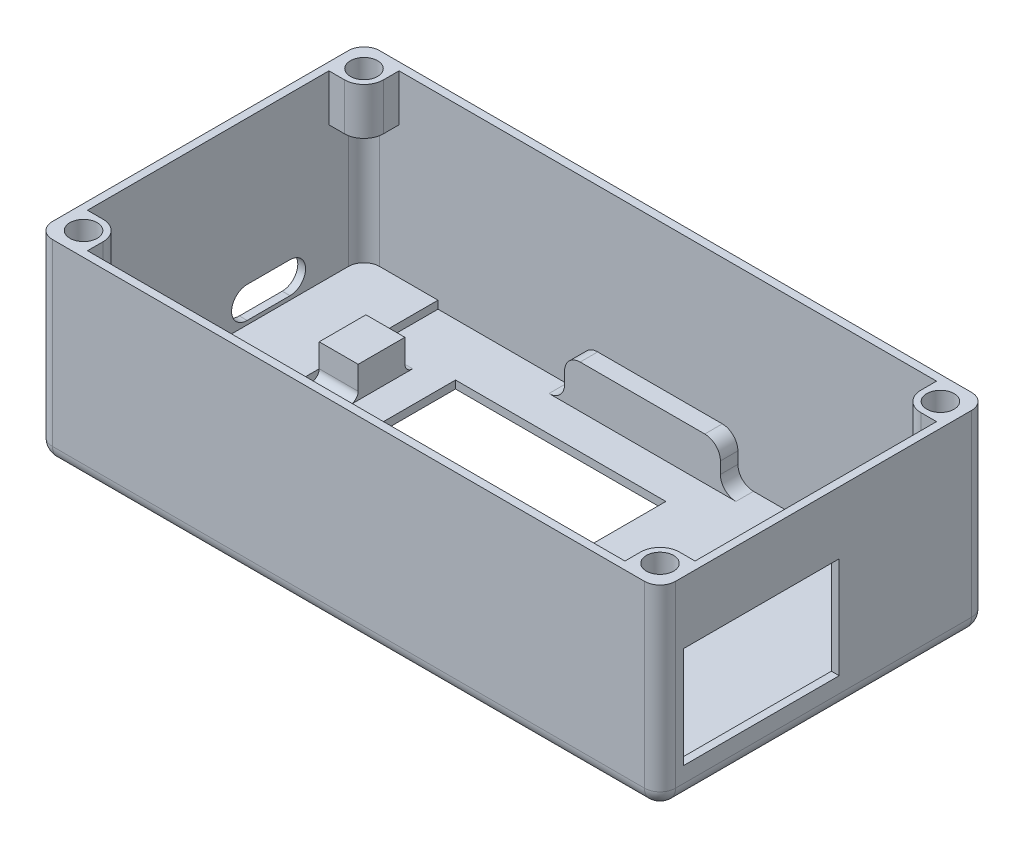
from build123d import *

# Parameters (mm, degrees)
SKETCH1_W               = 80
SKETCH1_H               = 42
BOSS_EXTRUDE1_DEPTH     = 25
SKETCH6_W               = 78
SKETCH6_H               = 40
CUT_EXTRUDE6_DEPTH      = 24
CUT_EXTRUDE7_REACH      = 53.157
SKETCH7_W               = 33.5
SKETCH7_H               = 20
SKETCH8_W               = 5
SKETCH8_H               = 6
BOSS_EXTRUDE2_DEPTH     = 4
SKETCH9_W               = 9.5
SKETCH9_H               = 25.25
BOSS_EXTRUDE3_DEPTH     = 1
FILLET1_R               = 1
FILLET3_R               = 2
CUT_EXTRUDE8_REACH      = 87.481
SKETCH18_W              = 20
SKETCH18_H              = 2.25
SKETCH18_H_2            = 3
BOSS_EXTRUDE5_DEPTH     = 5.5
FILLET5_R               = 2
CUT_EXTRUDE12_REACH     = 88.406
BOSS_EXTRUDE6_DEPTH     = 6
CUT_EXTRUDE13_REACH     = 53.633
SKETCH22_R              = 1.75
MIRROR3_COPY_1_DEPTH    = 6
MIRROR3_COPY_2_REACH    = 53.633
MIRROR3_COPY_2_SKETCH_R = 1.75
FILLET6_R               = 2
BOSS_EXTRUDE7_DEPTH     = 1
CUT_EXTRUDE14_REACH     = 88.406
SKETCH24_W              = 20
SKETCH24_H              = 13


with BuildPart() as part:
    # Sketch1 → Boss-Extrude1 (new body)
    with BuildSketch(Plane(origin=(0, 0, 0), x_dir=(1, 0, 0), z_dir=(0, 1, 0))):
        Rectangle(SKETCH1_W, SKETCH1_H)
    extrude(amount=BOSS_EXTRUDE1_DEPTH)

    # Sketch6 → Cut-Extrude6 (cut)
    with BuildSketch(Plane(origin=(0, 25, 0), x_dir=(1, 0, 0), z_dir=(0, 1, 0))):
        Rectangle(SKETCH6_W, SKETCH6_H)
    extrude(amount=-CUT_EXTRUDE6_DEPTH, mode=Mode.SUBTRACT)

    # Sketch7 → Cut-Extrude7 (cut, up to next)
    with BuildSketch(Plane(origin=(0, 1, 0), x_dir=(1, 0, 0), z_dir=(0, 1, 0)), mode=Mode.PRIVATE) as cut_extrude7_sk1:
        with Locations((-7.75, 7.75)):
            Rectangle(SKETCH7_W, SKETCH7_H)
    cut_extrude7_tool1 = extrude(cut_extrude7_sk1.sketch, amount=-CUT_EXTRUDE7_REACH, mode=Mode.PRIVATE) & part.part
    add(cut_extrude7_tool1.solids().sort_by_distance((-7.75, 1, -7.75))[0], mode=Mode.SUBTRACT)

    # Sketch8 → Boss-Extrude2 (add)
    with BuildSketch(Plane(origin=(0, 1, 0), x_dir=(1, 0, 0), z_dir=(0, 1, 0))):
        with Locations((-27, 7.75)):
            Rectangle(SKETCH8_W, SKETCH8_H)
    extrude(amount=BOSS_EXTRUDE2_DEPTH)

    # Sketch9 → Boss-Extrude3 (add)
    with BuildSketch(Plane(origin=(0, 1, 0), x_dir=(1, 0, 0), z_dir=(0, 1, 0))):
        with Locations((-34.25, 7.375)):
            Rectangle(SKETCH9_W, SKETCH9_H)
    extrude(amount=BOSS_EXTRUDE3_DEPTH)

    # Fillet1
    fillet1_edges = [part.edges().sort_by_distance(p)[0] for p in [
        (-27, 1, -10.75),
        (-27, 1, -4.75),
    ]]
    fillet(fillet1_edges, radius=FILLET1_R)

    # Fillet3
    fillet3_edges = [part.edges().sort_by_distance(p)[0] for p in [
        (-39, 13, 20),
        (39, 13, 20),
        (39, 13, -20),
        (-39, 13.5, -20),
        (40, 12.5, 21),
        (-40, 12.5, 21),
        (-40, 12.5, -21),
        (40, 12.5, -21),
    ]]
    fillet(fillet3_edges, radius=FILLET3_R)

    # Sketch12 → Cut-Extrude8 (cut, up to next)
    with BuildSketch(Plane(origin=(-39, 0, 0), x_dir=(0, 0, -1), z_dir=(1, 0, 0)), mode=Mode.PRIVATE) as cut_extrude8_sk1:
        with BuildLine():
            Line((5, 6.5), (10.5, 6.5))
            ThreePointArc((10.5, 6.5), (12.5, 4.5), (10.5, 2.5))
            Line((10.5, 2.5), (5, 2.5))
            ThreePointArc((5, 2.5), (3, 4.5), (5, 6.5))
        make_face()
    cut_extrude8_tool1 = extrude(cut_extrude8_sk1.sketch, amount=-CUT_EXTRUDE8_REACH, mode=Mode.PRIVATE) & part.part
    add(cut_extrude8_tool1.solids().sort_by_distance((-39, 4.5, -7.75))[0], mode=Mode.SUBTRACT)

    # Sketch18 → Boss-Extrude5 (add)
    with BuildSketch(Plane(origin=(0, 1, 0), x_dir=(1, 0, 0), z_dir=(0, 1, 0))):
        with Locations((-1, 18.875)):
            Rectangle(SKETCH18_W, SKETCH18_H)
        with Locations((-1, -3.75)):
            Rectangle(SKETCH18_W, SKETCH18_H_2)
    extrude(amount=BOSS_EXTRUDE5_DEPTH)

    # Fillet5
    fillet5_edges = [part.edges().sort_by_distance(p)[0] for p in [
        (9, 1, -18.875),
        (-11, 1, -18.875),
        (9, 6.5, -18.875),
        (-11, 6.5, -18.875),
        (9, 1, 3.75),
        (-11, 1, 3.75),
        (9, 6.5, 3.75),
        (-11, 6.5, 3.75),
    ]]
    fillet(fillet5_edges, radius=FILLET5_R)

    # Sketch19 → Cut-Extrude12 (cut, up to next)
    with BuildSketch(Plane.ZY.offset(40), mode=Mode.PRIVATE) as cut_extrude12_sk1:
        with BuildLine():
            Line((10, 8.75), (10, 6.25))
            ThreePointArc((10, 6.25), (16.25, 7.5), (10, 8.75))
        make_face()
    cut_extrude12_tool1 = extrude(cut_extrude12_sk1.sketch, amount=-CUT_EXTRUDE12_REACH, mode=Mode.PRIVATE) & part.part
    add(cut_extrude12_tool1.solids().sort_by_distance((-40, 7.5, 13.039742))[0], mode=Mode.SUBTRACT)

    # Sketch20 → Boss-Extrude6 (add)
    with BuildSketch(Plane(origin=(0, 25, 0), x_dir=(1, 0, 0), z_dir=(0, 1, 0))):
        with BuildLine():
            Line((-34.5, 20), (-37, 20))
            ThreePointArc((-37, 20), (-38.414213562, 19.414213562), (-39, 18))
            Line((-39, 18), (-39, 15.5))
            Line((-39, 15.5), (-37, 15.5))
            ThreePointArc((-37, 15.5), (-35.232233047, 16.232233047), (-34.5, 18))
            Line((-34.5, 18), (-34.5, 20))
        make_face()
    boss_extrude6 = extrude(amount=-BOSS_EXTRUDE6_DEPTH)

    # Sketch22 → Cut-Extrude13 (cut, up to next)
    with BuildSketch(Plane(origin=(0, 25, 0), x_dir=(1, 0, 0), z_dir=(0, 1, 0)), mode=Mode.PRIVATE) as cut_extrude13_sk1:
        with Locations(Location((-37, 18, 0), (0, 0, 270))):
            Circle(SKETCH22_R)
    cut_extrude13_tool1 = extrude(cut_extrude13_sk1.sketch, amount=-CUT_EXTRUDE13_REACH, mode=Mode.PRIVATE) & part.part
    cut_extrude13 = cut_extrude13_tool1.solids().sort_by_distance((-37, 25, -18))[0]
    add(cut_extrude13, mode=Mode.SUBTRACT)

    # Mirror1: Boss-Extrude6, Cut-Extrude13 across plane
    add(boss_extrude6.mirror(Plane.XY))
    add(cut_extrude13.mirror(Plane.XY), mode=Mode.SUBTRACT)

    # Mirror3: Boss-Extrude6, Cut-Extrude13 across plane
    add(boss_extrude6.mirror(Plane(origin=(0, 0, 0), x_dir=(0, 0, 1), z_dir=(1, 0, 0))))
    add(cut_extrude13.mirror(Plane(origin=(0, 0, 0), x_dir=(0, 0, 1), z_dir=(1, 0, 0))), mode=Mode.SUBTRACT)

    # Mirror3 copy 1 sketch → Mirror3 copy 1 (add)
    with BuildSketch(Plane(origin=(0, 25, 0), x_dir=(-1, 0, 0), z_dir=(0, 1, 0))):
        with BuildLine():
            Line((-34.5, 20), (-37, 20))
            ThreePointArc((-37, 20), (-38.414213562, 19.414213562), (-39, 18))
            Line((-39, 18), (-39, 15.5))
            Line((-39, 15.5), (-37, 15.5))
            ThreePointArc((-37, 15.5), (-35.232233047, 16.232233047), (-34.5, 18))
            Line((-34.5, 18), (-34.5, 20))
        make_face()
    extrude(amount=-MIRROR3_COPY_1_DEPTH)

    # Mirror3 copy 2 sketch → Mirror3 copy 2 (cut, up to next)
    with BuildSketch(Plane(origin=(0, 25, 0), x_dir=(-1, 0, 0), z_dir=(0, 1, 0)), mode=Mode.PRIVATE) as mirror3_copy_2_sk1:
        with Locations(Location((-37, 18, 0), (0, 0, 270))):
            Circle(MIRROR3_COPY_2_SKETCH_R)
    mirror3_copy_2_tool1 = extrude(mirror3_copy_2_sk1.sketch, amount=-MIRROR3_COPY_2_REACH, mode=Mode.PRIVATE) & part.part
    add(mirror3_copy_2_tool1.solids().sort_by_distance((37, 25, 18))[0], mode=Mode.SUBTRACT)

    # Fillet6
    fillet6_edges = [part.edges().sort_by_distance(p)[0] for p in [
        (0, 0, -21),
        (40, 0, 0),
        (0, 0, 21),
        (-40, 0, 0),
        (39.414213562, 0, 20.414213562),
        (-39.414213562, 0, 20.414213562),
        (-39.414213562, 0, -20.414213562),
        (39.414213562, 0, -20.414213562),
    ]]
    fillet(fillet6_edges, radius=FILLET6_R)

    # Sketch23 → Boss-Extrude7 (add)
    with BuildSketch(Plane.XZ):
        Polygon((-20.5, 2.25), (-20.5, -13.25), (6.5, -13.25), (6.5, 2.25), (9, 2.25), (9, -17.75), (-24.5, -17.75), (-24.5, 2.25), align=None)
    extrude(amount=-BOSS_EXTRUDE7_DEPTH)

    # Sketch24 → Cut-Extrude14 (cut, up to next)
    with BuildSketch(Plane(origin=(40, 0, 0), x_dir=(0, 0, -1), z_dir=(1, 0, 0)), mode=Mode.PRIVATE) as cut_extrude14_sk1:
        with Locations((-8, 10.5)):
            Rectangle(SKETCH24_W, SKETCH24_H)
    cut_extrude14_tool1 = extrude(cut_extrude14_sk1.sketch, amount=-CUT_EXTRUDE14_REACH, mode=Mode.PRIVATE) & part.part
    add(cut_extrude14_tool1.solids().sort_by_distance((40, 10.5, 8))[0], mode=Mode.SUBTRACT)


solid = part.part
